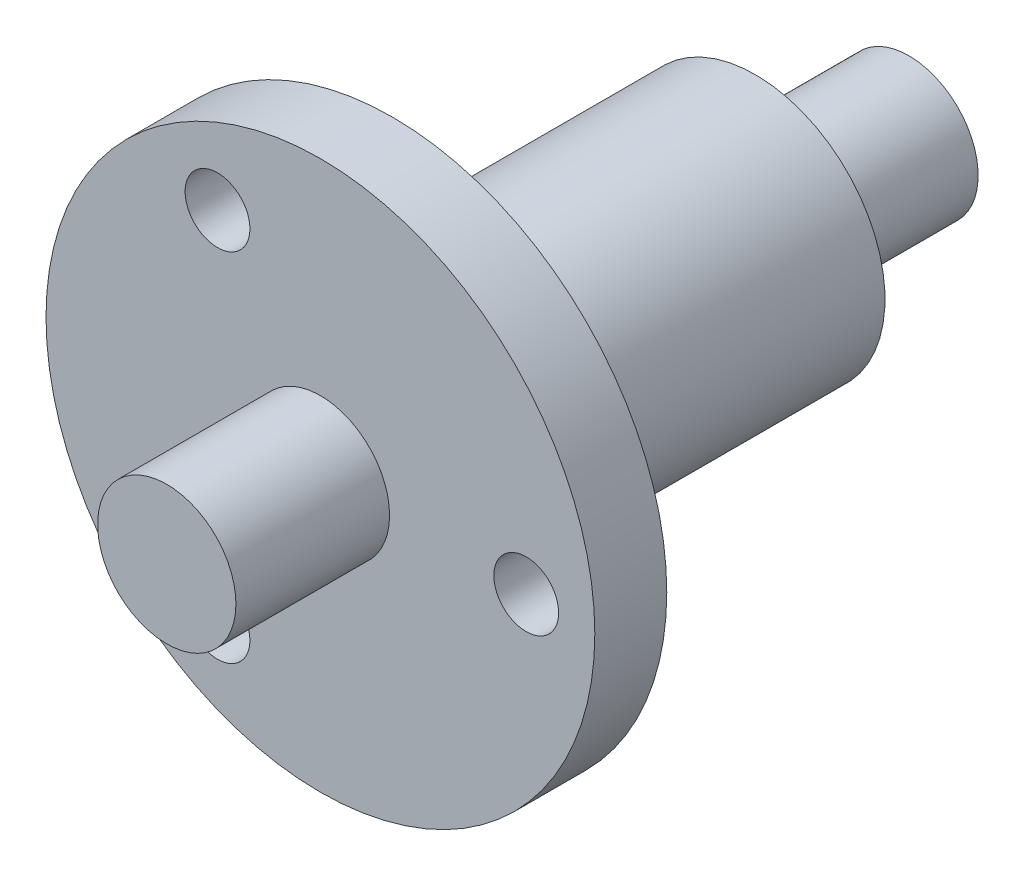
from build123d import *

# Parameters (mm, degrees)
SKETCH1_R           = 12.7
BOSS_EXTRUDE1_DEPTH = 3.33
SKETCH2_R           = 3.2
BOSS_EXTRUDE2_DEPTH = 7.11
SKETCH3_R           = 6
BOSS_EXTRUDE3_DEPTH = 16.8
SKETCH4_R           = 3.2
BOSS_EXTRUDE4_DEPTH = 7.11
SKETCH5_R           = 1.5
CUT_EXTRUDE1_DEPTH  = 7.11


with BuildPart() as part:
    # Sketch1 → Boss-Extrude1 (new body)
    with BuildSketch(Plane.XY):
        Circle(SKETCH1_R)
    extrude(amount=BOSS_EXTRUDE1_DEPTH)

    # Sketch2 → Boss-Extrude2 (add)
    with BuildSketch(Plane.XY.offset(3.33)):
        Circle(SKETCH2_R)
    extrude(amount=BOSS_EXTRUDE2_DEPTH)

    # Sketch3 → Boss-Extrude3 (add)
    with BuildSketch(Plane(origin=(0, 0, 0), x_dir=(-1, 0, 0), z_dir=(0, 0, -1))):
        Circle(SKETCH3_R)
    extrude(amount=BOSS_EXTRUDE3_DEPTH)

    # Sketch4 → Boss-Extrude4 (add)
    with BuildSketch(Plane(origin=(0, 0, -16.8), x_dir=(-1, 0, 0), z_dir=(0, 0, -1))):
        Circle(SKETCH4_R)
    extrude(amount=BOSS_EXTRUDE4_DEPTH)

    # Sketch5 → Cut-Extrude1 (cut)
    with BuildSketch(Plane.XY.offset(3.33)):
        with Locations((9.525, 0)):
            Circle(SKETCH5_R)
        with Locations((-4.7625, -8.248891971)):
            Circle(SKETCH5_R)
        with Locations((-4.7625, 8.248891971)):
            Circle(SKETCH5_R)
    extrude(amount=-CUT_EXTRUDE1_DEPTH, mode=Mode.SUBTRACT)


solid = part.part
